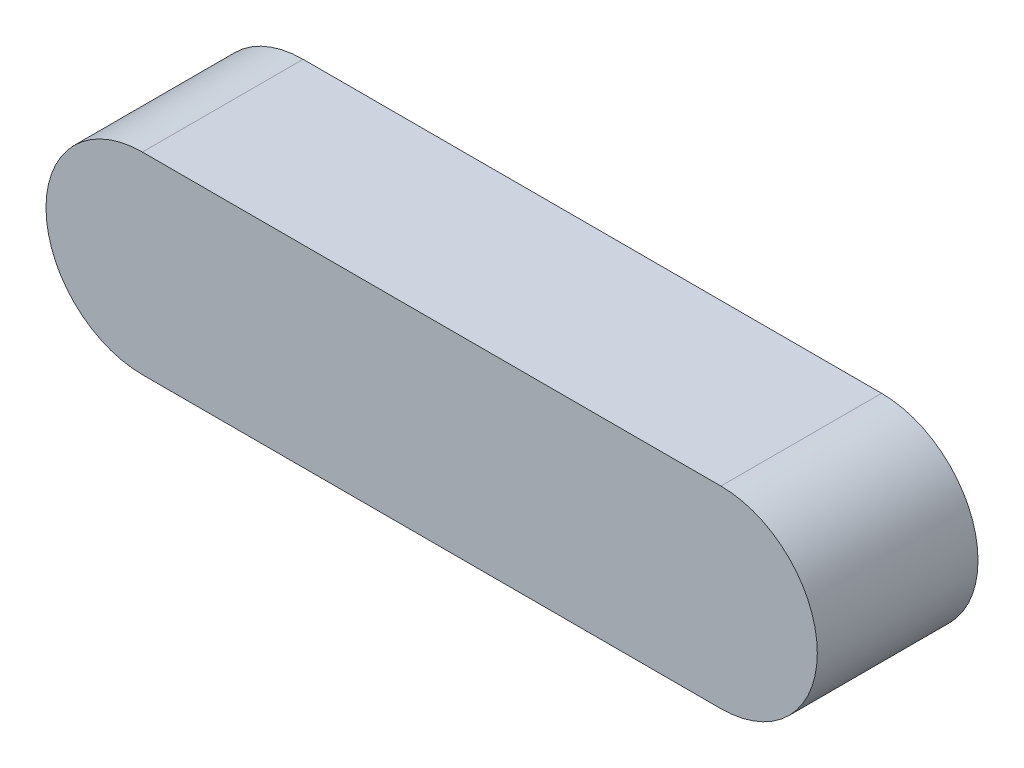
from build123d import *

# Parameters (mm, degrees)
BOSS_EXTRUDE1_DEPTH = 63.5


with BuildPart() as part:
    # Sketch1 → Boss-Extrude1 (new body)
    with BuildSketch(Plane.XY):
        with BuildLine():
            Line((0, 38.1), (228.6, 38.1))
            ThreePointArc((228.6, 38.1), (266.7, 0), (228.6, -38.1))
            Line((228.6, -38.1), (0, -38.1))
            ThreePointArc((0, -38.1), (-38.1, 0), (0, 38.1))
        make_face()
    extrude(amount=BOSS_EXTRUDE1_DEPTH)


solid = part.part
